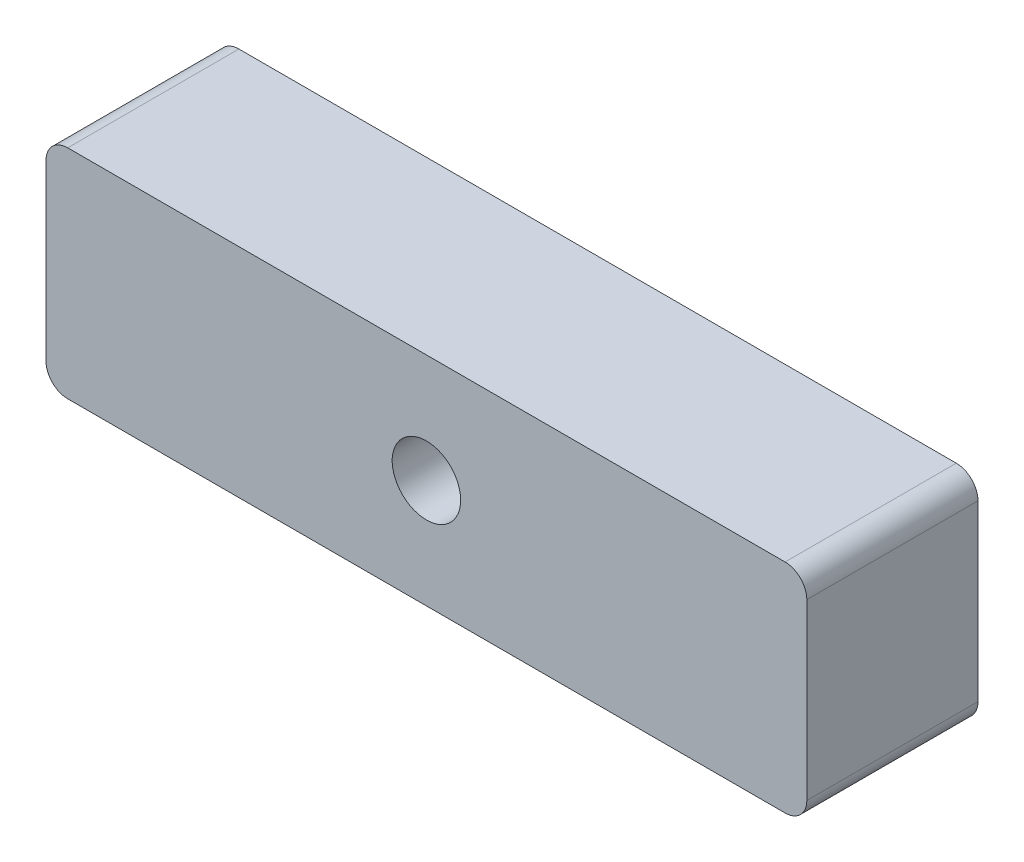
from build123d import *

# Parameters (mm, degrees)
BOSS_EXTRUDE1_DEPTH = 20
SKETCH3_R           = 4
CUT_EXTRUDE1_DEPTH  = 20


with BuildPart() as part:
    # Sketch2 → Boss-Extrude1 (new body)
    with BuildSketch(Plane.XY):
        with BuildLine():
            Line((-41.91, -12.7), (41.91, -12.7))
            ThreePointArc((41.91, -12.7), (43.706051224, -11.956051224), (44.45, -10.16))
            Line((44.45, -10.16), (44.45, 10.16))
            ThreePointArc((44.45, 10.16), (43.706051224, 11.956051224), (41.91, 12.7))
            Line((41.91, 12.7), (-41.91, 12.7))
            ThreePointArc((-41.91, 12.7), (-43.706051224, 11.956051224), (-44.45, 10.16))
            Line((-44.45, 10.16), (-44.45, -10.16))
            ThreePointArc((-44.45, -10.16), (-43.706051224, -11.956051224), (-41.91, -12.7))
        make_face()
    extrude(amount=BOSS_EXTRUDE1_DEPTH)

    # Sketch3 → Cut-Extrude1 (cut)
    with BuildSketch(Plane.XY.offset(20)):
        Circle(SKETCH3_R)
    extrude(amount=-CUT_EXTRUDE1_DEPTH, mode=Mode.SUBTRACT)


solid = part.part
